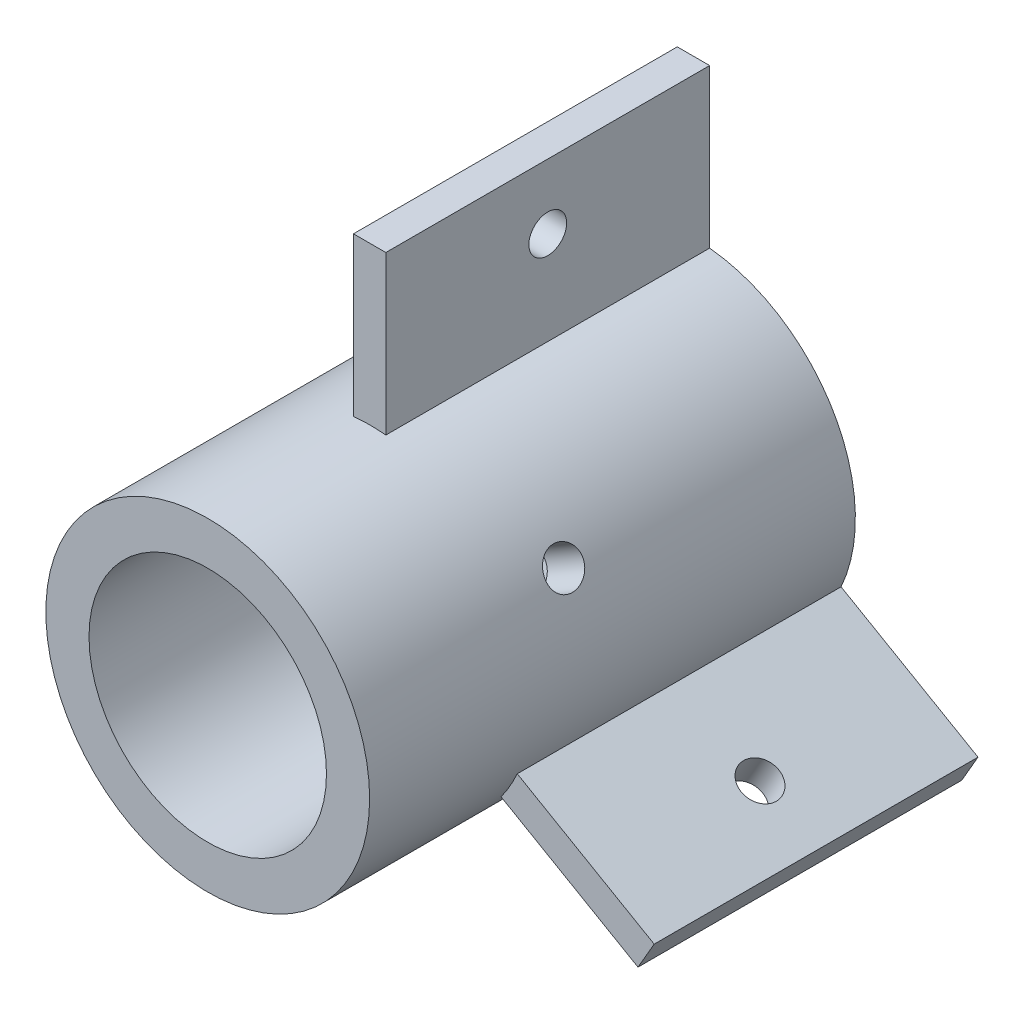
from build123d import *

# Parameters (mm, degrees)
SKETCH_1_R               = 15
EXTRUDE_1_DEPTH          = 45
SKETCH_2_R               = 11
CUT_EXTRUDE_1_DEPTH      = 40
SKETCH_3_R               = 7.5
CUT_EXTRUDE_2_DEPTH      = 5
SKETCH_4_W               = 3
SKETCH_4_H               = 15
EXTRUDE_2_DEPTH          = 30
SKETCH_5_R               = 1.75
CUT_EXTRUDE_3_DEPTH      = 30
SKETCH_6_R               = 1.75
CUT_EXTRUDE_4_DEPTH      = 30
SKETCH_7_R               = 1.75
CUT_EXTRUDE_5_DEPTH      = 30
SKETCH_8_R               = 1.75
CUT_EXTRUDE_6_DEPTH      = 10
PATTERN_CIRCULAR_1_COUNT = 3


with BuildPart() as part:
    # 草圖1 → 填料-伸長1 (new body)
    with BuildSketch(Plane.XY):
        Circle(SKETCH_1_R)
    extrude(amount=EXTRUDE_1_DEPTH)

    # 草圖2 → 除料-伸長1 (cut)
    with BuildSketch(Plane.XY.offset(45)):
        Circle(SKETCH_2_R)
    extrude(amount=-CUT_EXTRUDE_1_DEPTH, mode=Mode.SUBTRACT)

    # 草圖3 → 除料-伸長2 (cut)
    with BuildSketch(Plane.XY.offset(5)):
        Circle(SKETCH_3_R)
    extrude(amount=-CUT_EXTRUDE_2_DEPTH, mode=Mode.SUBTRACT)

    # 草圖4 → 填料-伸長2 (add)
    with BuildSketch(Plane.XY):
        Polygon((26.361016738, -13.487489302), (13.370635681, -5.987489302), (11.870635681, -8.585565513), (24.861016738, -16.085565513), align=None)
        with Locations((0, 22.073054816)):
            Rectangle(SKETCH_4_W, SKETCH_4_H)
        Polygon((-24.861016738, -16.085565513), (-11.870635681, -8.585565513), (-13.370635681, -5.987489302), (-26.361016738, -13.487489302), align=None)
    extrude(amount=EXTRUDE_2_DEPTH)

    # 草圖5 → 除料-伸長3 (cut)
    with BuildSketch(Plane(origin=(-0.75, -1.299038106, 0), x_dir=(0.866025404, -0.5, 0), z_dir=(-0.5, -0.866025404, 0))):
        with Locations((23.573054816, 15)):
            Circle(SKETCH_5_R)
    extrude(amount=-CUT_EXTRUDE_3_DEPTH, mode=Mode.SUBTRACT)

    # 草圖6 → 除料-伸長4 (cut)
    with BuildSketch(Plane(origin=(1.5, 0, 0), x_dir=(0, 0, -1), z_dir=(1, 0, 0))):
        with Locations((-15, 23.573054816)):
            Circle(SKETCH_6_R)
    extrude(amount=-CUT_EXTRUDE_4_DEPTH, mode=Mode.SUBTRACT)

    # 草圖7 → 除料-伸長5 (cut)
    with BuildSketch(Plane(origin=(-0.75, 1.299038106, 0), x_dir=(0.866025404, 0.5, 0), z_dir=(-0.5, 0.866025404, 0))):
        with Locations((-23.573054816, -15)):
            Circle(SKETCH_7_R)
    extrude(amount=-CUT_EXTRUDE_5_DEPTH, mode=Mode.SUBTRACT)

    # 草圖8 → 除料-伸長6 (cut)
    with BuildSketch(Plane(origin=(0, -15, 0), x_dir=(0, 0, -1), z_dir=(0, -1, 0))):
        with Locations((-25, 0)):
            Circle(SKETCH_8_R)
    cut_extrude_6 = extrude(amount=-CUT_EXTRUDE_6_DEPTH, mode=Mode.SUBTRACT)

    # 環狀複製排列1: 除料-伸長6 ×3 about axis
    pattern_circular_1_axis = Axis((0, 0, 0), (0, 0, 1))
    for i in range(1, PATTERN_CIRCULAR_1_COUNT):
        add(cut_extrude_6.rotate(pattern_circular_1_axis, i * 360 / PATTERN_CIRCULAR_1_COUNT), mode=Mode.SUBTRACT)


solid = part.part
